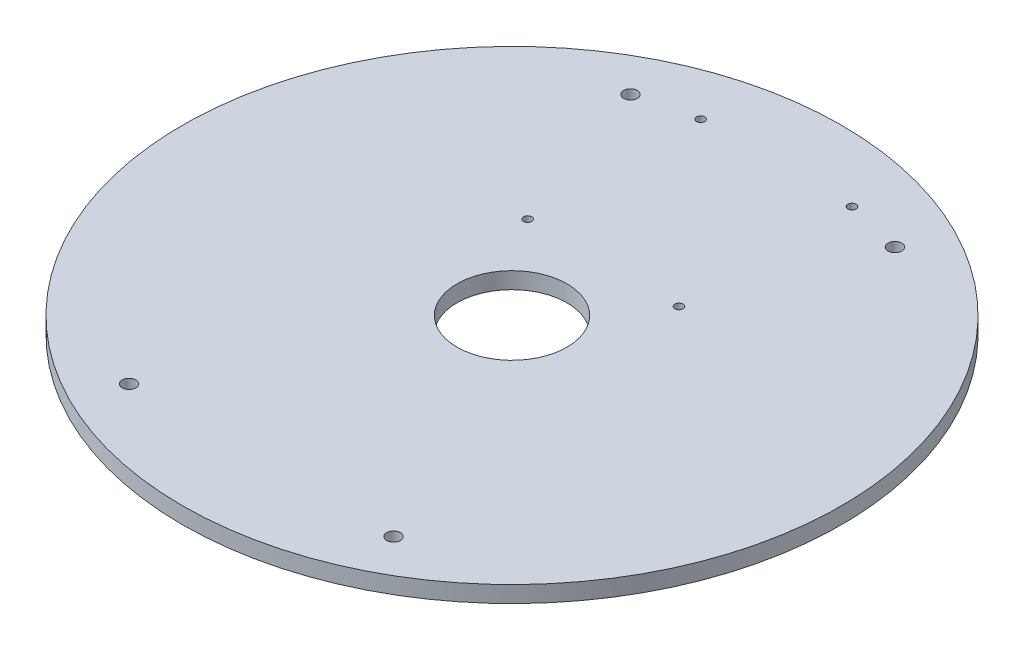
from build123d import *

# Parameters (mm, degrees)
SKETCH1_R           = 60
BOSS_EXTRUDE1_DEPTH = 3
SKETCH2_R           = 1.25
CUT_EXTRUDE1_DEPTH  = 4
SKETCH5_R           = 10
CUT_EXTRUDE2_DEPTH  = 4
SKETCH6_R           = 0.75
CUT_EXTRUDE3_DEPTH  = 4


with BuildPart() as part:
    # Sketch1 → Boss-Extrude1 (new body)
    with BuildSketch(Plane(origin=(0, 0, 0), x_dir=(1, 0, 0), z_dir=(0, 1, 0))):
        Circle(SKETCH1_R)
    extrude(amount=BOSS_EXTRUDE1_DEPTH)

    # Sketch2 → Cut-Extrude1 (cut, through all)
    with BuildSketch(Plane(origin=(0, 3, 0), x_dir=(1, 0, 0), z_dir=(0, 1, 0))):
        with Locations((-24.073102507, 45.644631202)):
            Circle(SKETCH2_R)
        with Locations((24.073102507, 45.644631202)):
            Circle(SKETCH2_R)
        with Locations((24.073102507, -45.644631202)):
            Circle(SKETCH2_R)
        with Locations((-24.073102507, -45.644631202)):
            Circle(SKETCH2_R)
    extrude(amount=-CUT_EXTRUDE1_DEPTH, mode=Mode.SUBTRACT)

    # Sketch5 → Cut-Extrude2 (cut, through all)
    with BuildSketch(Plane(origin=(0, 3, 0), x_dir=(1, 0, 0), z_dir=(0, 1, 0))):
        Circle(SKETCH5_R)
    extrude(amount=-CUT_EXTRUDE2_DEPTH, mode=Mode.SUBTRACT)

    # Sketch6 → Cut-Extrude3 (cut, through all)
    with BuildSketch(Plane(origin=(0, 3, 0), x_dir=(1, 0, 0), z_dir=(0, 1, 0))):
        with Locations((13.773714056, 48.12077632)):
            Circle(SKETCH6_R)
        with Locations((13.773714056, 16.62077632)):
            Circle(SKETCH6_R)
        with Locations((-13.773714056, 16.62077632)):
            Circle(SKETCH6_R)
        with Locations((-13.773714056, 48.12077632)):
            Circle(SKETCH6_R)
    extrude(amount=-CUT_EXTRUDE3_DEPTH, mode=Mode.SUBTRACT)


solid = part.part
